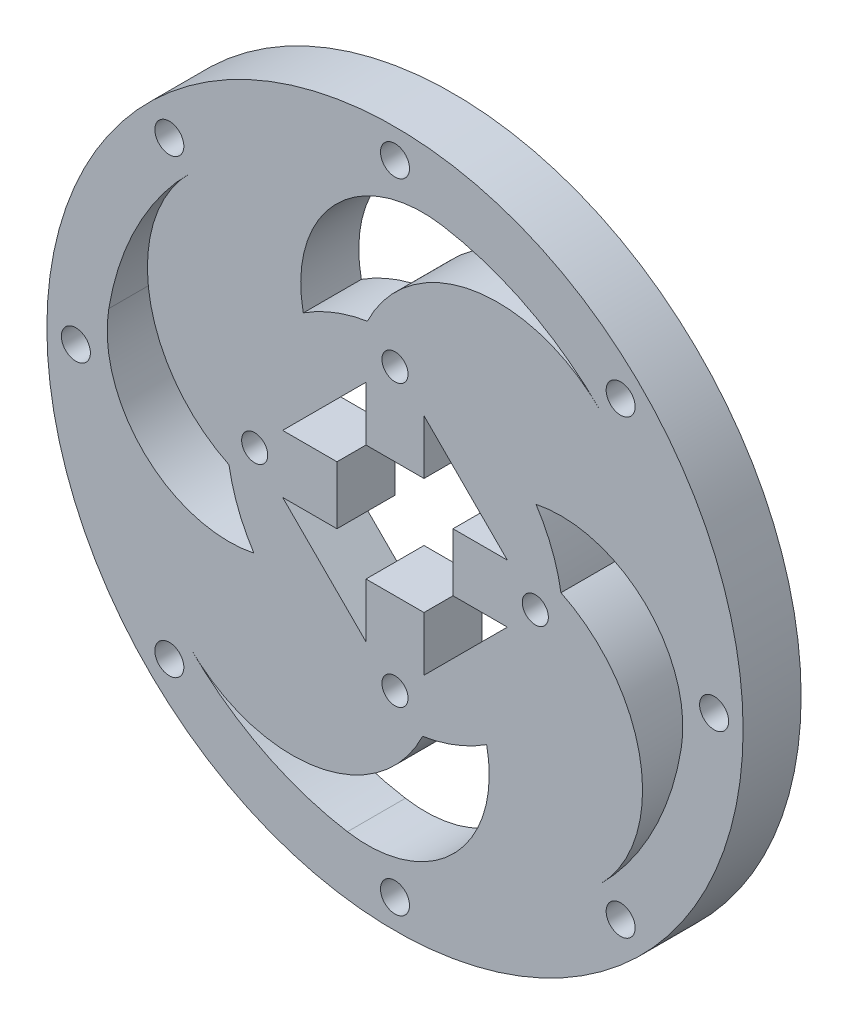
from build123d import *

# Parameters (mm, degrees)
SKETCH6_R                        = 29
SKETCH6_R_2                      = 20
INNER_RING_DEPTH                 = 10
MOTOR_CONNECTOR_CUT_DEPTH        = 10
SKETCH8_R                        = 2.25
MOTOR_CONNECTOR_HOLES_DEPTH      = 1
MOTOR_CONNECTOR_HOLES_DEPTH_BACK = 18
MIDDLE_PATTERN_DEPTH             = 10
SKETCH9_R                        = 60
SKETCH9_R_2                      = 50
SKETCH9_R_3                      = 2.5
BOSS_EXTRUDE1_DEPTH              = 10
BOSS_EXTRUDE2_DEPTH              = 10


with BuildPart() as part:
    # Sketch6 → Inner Ring (new body)
    with BuildSketch(Plane.XY):
        Circle(SKETCH6_R)
        Circle(SKETCH6_R_2, mode=Mode.SUBTRACT)
    extrude(amount=-INNER_RING_DEPTH)

    # Sketch7 → Motor Connector Cut (add)
    with BuildSketch(Plane.XY):
        with BuildLine():
            ThreePointArc((20, 0), (19.840593925, 2.52008585), (19.364916731, 5))
            Line((19.364916731, 5), (9.999996731, 5))
            Line((9.999996731, 5), (9.999996731, -5))
            Line((9.999996731, -5), (19.364916731, -5))
            ThreePointArc((19.364916731, -5), (19.840593925, -2.52008585), (20, 0))
        make_face()
        with BuildLine():
            ThreePointArc((5, 19.364916731), (0, 20), (-5, 19.364916731))
            Line((-5, 19.364916731), (-5, 9.999996731))
            Line((-5, 9.999996731), (5, 9.999996731))
            Line((5, 9.999996731), (5, 19.364916731))
        make_face()
        with BuildLine():
            Line((-9.999996731, -5), (-9.999996731, 5))
            Line((-9.999996731, 5), (-19.364916731, 5))
            ThreePointArc((-19.364916731, 5), (-20, 0), (-19.364916731, -5))
            Line((-19.364916731, -5), (-9.999996731, -5))
        make_face()
        with BuildLine():
            Line((-5, -9.999996731), (-5, -19.364916731))
            ThreePointArc((-5, -19.364916731), (0, -20), (5, -19.364916731))
            Line((5, -19.364916731), (5, -9.999996731))
            Line((5, -9.999996731), (-5, -9.999996731))
        make_face()
    extrude(amount=-MOTOR_CONNECTOR_CUT_DEPTH)

    # Sketch8 → Motor Connector Holes (cut, two sides)
    with BuildSketch(Plane.XY) as motor_connector_holes_sk:
        with Locations((0, 24.182458366)):
            Circle(SKETCH8_R)
        with Locations((24.182458366, 0)):
            Circle(SKETCH8_R)
        with Locations((0, -24.182458366)):
            Circle(SKETCH8_R)
        with Locations((-24.182458366, 0)):
            Circle(SKETCH8_R)
    extrude(amount=MOTOR_CONNECTOR_HOLES_DEPTH, mode=Mode.SUBTRACT)
    extrude(motor_connector_holes_sk.sketch, amount=-MOTOR_CONNECTOR_HOLES_DEPTH_BACK, mode=Mode.SUBTRACT)

    # Sketch10 → Middle Pattern (add)
    with BuildSketch(Plane.XY):
        with BuildLine():
            ThreePointArc((28.607215414, 4.756808408), (26.539406056, -11.690163651), (15.800414568, -24.317625284))
            ThreePointArc((15.800414568, -24.317625284), (10.393277118, -43.149392299), (-8.201394307, -49.322785114))
            ThreePointArc((-8.201394307, -49.322785114), (15.267827816, -47.611904328), (35.355339059, -35.355339059))
            ThreePointArc((35.355339059, -35.355339059), (42.321804958, -13.559663633), (28.607215414, 4.756808408))
        make_face()
        with BuildLine():
            ThreePointArc((24.317625284, 15.800414568), (43.149392359, 10.39327706), (49.322785087, -8.201394473))
            ThreePointArc((49.322785087, -8.201394473), (47.611904354, 15.267827736), (35.355339059, 35.355339059))
            ThreePointArc((35.355339059, 35.355339059), (13.559663633, 42.321804958), (-4.756808408, 28.607215414))
            ThreePointArc((-4.756808408, 28.607215414), (11.690163651, 26.539406056), (24.317625284, 15.800414568))
        make_face()
        with BuildLine():
            ThreePointArc((8.201394106, 49.322785148), (-15.267827902, 47.611904301), (-35.355339044, 35.355339075))
            ThreePointArc((-35.355339044, 35.355339075), (-42.32180496, 13.559663644), (-28.607215414, -4.756808408))
            ThreePointArc((-28.607215414, -4.756808408), (-26.539406056, 11.690163651), (-15.800414568, 24.317625284))
            ThreePointArc((-15.800414568, 24.317625284), (-10.393277189, 43.149392225), (8.201394106, 49.322785148))
        make_face()
        with BuildLine():
            ThreePointArc((4.756808408, -28.607215414), (-11.690163651, -26.539406056), (-24.317625284, -15.800414568))
            ThreePointArc((-24.317625284, -15.800414568), (-43.149392012, -10.393277393), (-49.322785244, 8.201393524))
            ThreePointArc((-49.322785244, 8.201393524), (-47.61190416, -15.267828343), (-35.355338839, -35.35533928))
            ThreePointArc((-35.355338839, -35.35533928), (-13.559663479, -42.321804932), (4.756808408, -28.607215414))
        make_face()
    extrude(amount=-MIDDLE_PATTERN_DEPTH)

    # Sketch9 → Boss-Extrude1 (add)
    with BuildSketch(Plane.XY):
        Circle(SKETCH9_R)
        Circle(SKETCH9_R_2, mode=Mode.SUBTRACT)
        with Locations((0, 55)):
            Circle(SKETCH9_R_3, mode=Mode.SUBTRACT)
        with Locations((-38.890872965, 38.890872965)):
            Circle(SKETCH9_R_3, mode=Mode.SUBTRACT)
        with Locations((-55, 0)):
            Circle(SKETCH9_R_3, mode=Mode.SUBTRACT)
        with Locations((-38.890872965, -38.890872965)):
            Circle(SKETCH9_R_3, mode=Mode.SUBTRACT)
        with Locations((0, -55)):
            Circle(SKETCH9_R_3, mode=Mode.SUBTRACT)
        with Locations((38.890872965, -38.890872965)):
            Circle(SKETCH9_R_3, mode=Mode.SUBTRACT)
        with Locations((55, 0)):
            Circle(SKETCH9_R_3, mode=Mode.SUBTRACT)
        with Locations((38.890872965, 38.890872965)):
            Circle(SKETCH9_R_3, mode=Mode.SUBTRACT)
    extrude(amount=-BOSS_EXTRUDE1_DEPTH)

    # Sketch11 → Boss-Extrude2 (add)
    with BuildSketch(Plane.XY):
        with BuildLine():
            Line((-19.364916731, 5), (-5, 19.364916731))
            ThreePointArc((-5, 19.364916731), (-14.142135624, 14.142135624), (-19.364916731, 5))
        make_face()
        with BuildLine():
            Line((5, 19.364916731), (19.364916731, 5))
            ThreePointArc((19.364916731, 5), (14.142135624, 14.142135624), (5, 19.364916731))
        make_face()
        with BuildLine():
            Line((19.364916731, -5), (5, -19.364916731))
            ThreePointArc((5, -19.364916731), (14.142135624, -14.142135624), (19.364916731, -5))
        make_face()
        with BuildLine():
            Line((-5, -19.364916731), (-19.364916731, -5))
            ThreePointArc((-19.364916731, -5), (-14.142135624, -14.142135624), (-5, -19.364916731))
        make_face()
    extrude(amount=-BOSS_EXTRUDE2_DEPTH)


solid = part.part
